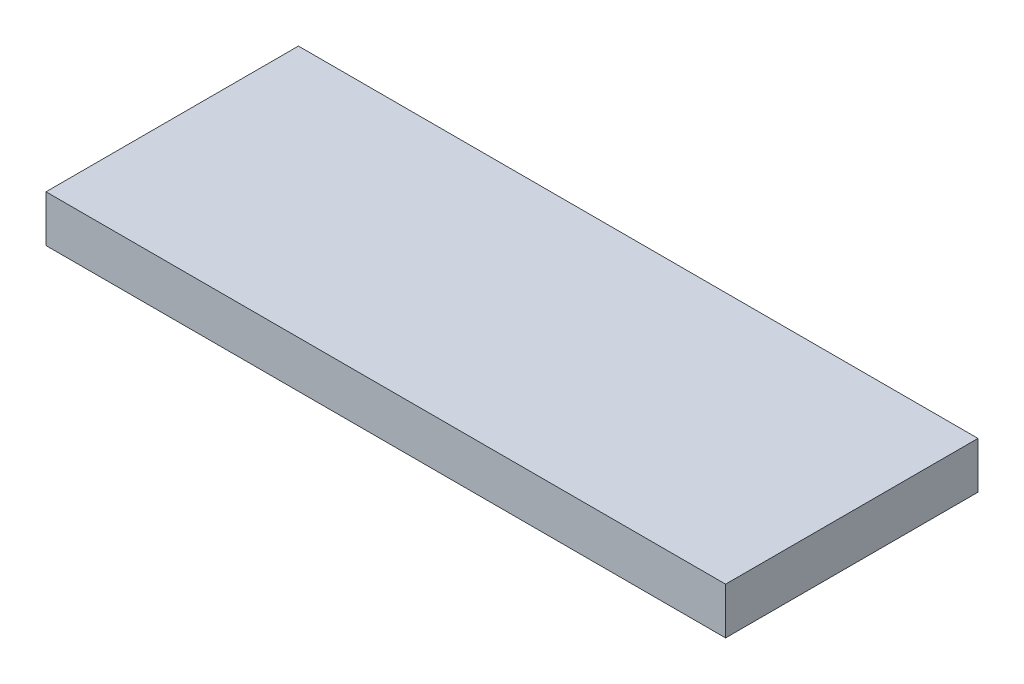
from build123d import *

# Parameters (mm, degrees)
SKETCH2_W           = 175
SKETCH2_H           = 65
BOSS_EXTRUDE1_DEPTH = 12


with BuildPart() as part:
    # Sketch2 → Boss-Extrude1 (new body)
    with BuildSketch(Plane(origin=(0, 0, 0), x_dir=(1, 0, 0), z_dir=(0, 1, 0))):
        with Locations((23.131108933, 6.268343816)):
            Rectangle(SKETCH2_W, SKETCH2_H)
    extrude(amount=BOSS_EXTRUDE1_DEPTH)


solid = part.part
